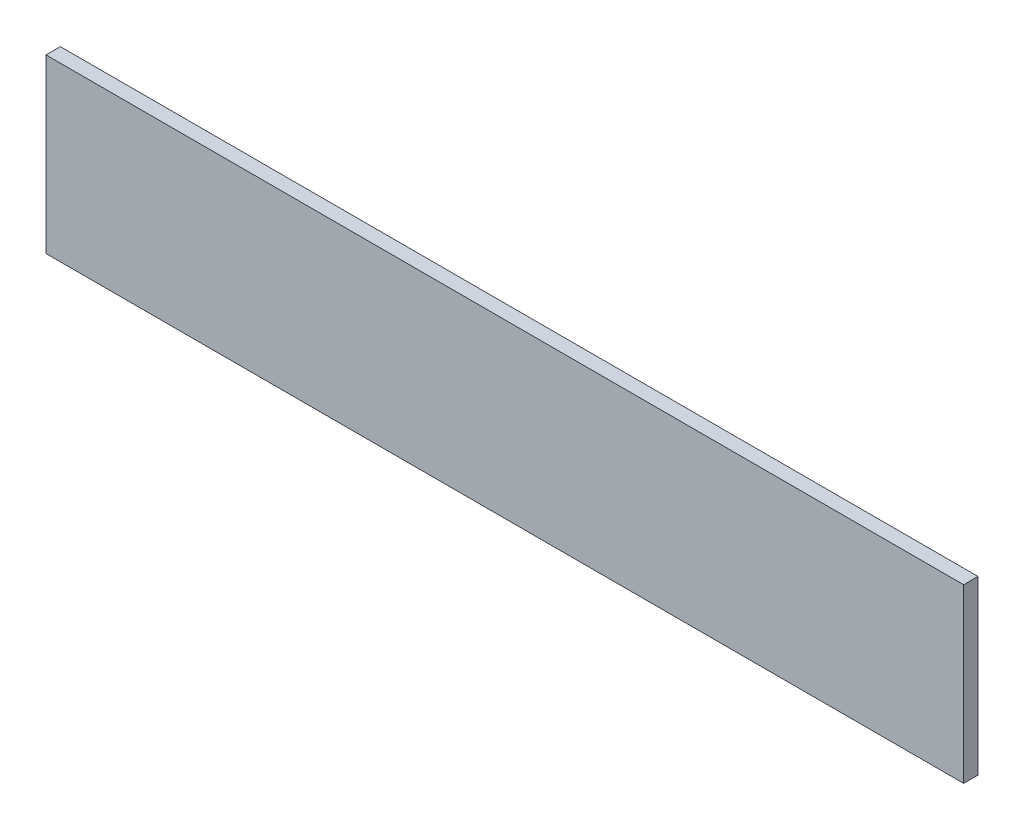
from build123d import *

# Parameters (mm, degrees)
SKETCH1_W           = 406.4
SKETCH1_H           = 76.2
BOSS_EXTRUDE1_DEPTH = 6.35


with BuildPart() as part:
    # Sketch1 → Boss-Extrude1 (new body)
    with BuildSketch(Plane.XY):
        with Locations((203.2, 38.1)):
            Rectangle(SKETCH1_W, SKETCH1_H)
    extrude(amount=BOSS_EXTRUDE1_DEPTH)


solid = part.part
